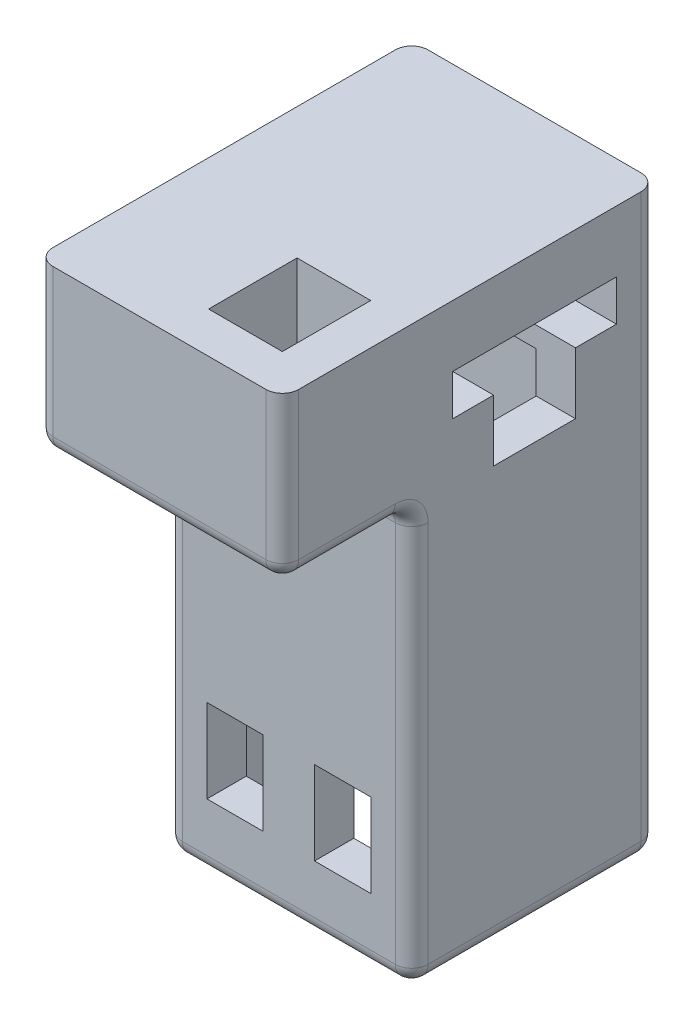
from build123d import *

# Parameters (mm, degrees)
SKETCH1_W           = 38.1
SKETCH1_H           = 38.1
BOSS_EXTRUDE1_DEPTH = 64.389
SKETCH2_W           = 8.720666582
SKETCH2_H           = 12.954
CUT_EXTRUDE1_DEPTH  = 38.1
SKETCH3_W           = 38.1
SKETCH3_H           = 38.1
BOSS_EXTRUDE2_DEPTH = 25.4
SKETCH1_3_W         = 25.908
SKETCH1_3_H         = 25.908
CUT_EXTRUDE2_DEPTH  = 70.739
CUT_EXTRUDE4_DEPTH  = 32.004
SKETCH7_W           = 38.1
SKETCH7_H           = 25.4
BOSS_EXTRUDE3_DEPTH = 20.066
SKETCH9_W           = 11.43
SKETCH9_H           = 13.716
CUT_EXTRUDE5_DEPTH  = 21.59
FILLET1_R           = 2.54


with BuildPart() as part:
    # Sketch1 → Boss-Extrude1 (new body)
    with BuildSketch(Plane(origin=(0, 0, 0), x_dir=(1, 0, 0), z_dir=(0, 1, 0))):
        Rectangle(SKETCH1_W, SKETCH1_H)
    extrude(amount=BOSS_EXTRUDE1_DEPTH)

    # Sketch2 → Cut-Extrude1 (cut)
    with BuildSketch(Plane.XY.offset(19.05)):
        with Locations((8.339666836, 16.637)):
            Rectangle(SKETCH2_W, SKETCH2_H)
        with Locations((-8.339666709, 16.637)):
            Rectangle(SKETCH2_W, SKETCH2_H)
    extrude(amount=-CUT_EXTRUDE1_DEPTH, mode=Mode.SUBTRACT)

    # Sketch3 → Boss-Extrude2 (add)
    with BuildSketch(Plane(origin=(0, 64.389, 0), x_dir=(-1, 0, 0), z_dir=(0, -1, 0))):
        Rectangle(SKETCH3_W, SKETCH3_H)
    extrude(amount=-BOSS_EXTRUDE2_DEPTH)

    # Sketch1_3 → Cut-Extrude2 (cut)
    with BuildSketch(Plane(origin=(0, 0, 0), x_dir=(1, 0, 0), z_dir=(0, 1, 0))):
        Rectangle(SKETCH1_3_W, SKETCH1_3_H)
    extrude(amount=CUT_EXTRUDE2_DEPTH, mode=Mode.SUBTRACT)

    # Sketch5 → Cut-Extrude4 (cut)
    with BuildSketch(Plane(origin=(19.05, 0, 0), x_dir=(0, 0, -1), z_dir=(1, 0, 0))):
        Polygon((-12.7, 80.264), (12.7, 80.264), (12.7, 73.914), (6.35, 73.914), (6.35, 64.389), (-6.35, 64.389), (-6.35, 73.914), (-12.7, 73.914), align=None)
    extrude(amount=-CUT_EXTRUDE4_DEPTH, mode=Mode.SUBTRACT)

    # Sketch7 → Boss-Extrude3 (add)
    with BuildSketch(Plane.XY.offset(19.05)):
        with Locations((0, 77.089)):
            Rectangle(SKETCH7_W, SKETCH7_H)
    extrude(amount=BOSS_EXTRUDE3_DEPTH)

    # Sketch9 → Cut-Extrude5 (cut)
    with BuildSketch(Plane(origin=(0, 89.789, 0), x_dir=(1, 0, 0), z_dir=(0, 1, 0))):
        with Locations((6.985, -25.908)):
            Rectangle(SKETCH9_W, SKETCH9_H)
    extrude(amount=-CUT_EXTRUDE5_DEPTH, mode=Mode.SUBTRACT)

    # Fillet1
    fillet1_edges = [part.edges().sort_by_distance(p)[0] for p in [
        (19.05, 32.1945, 19.05),
        (-19.05, 32.1945, 19.05),
        (0, 64.389, 19.05),
        (-19.05, 64.389, 29.083),
        (19.05, 64.389, 29.083),
        (-19.05, 77.089, 39.116),
        (0, 64.389, 39.116),
        (19.05, 77.089, 39.116),
        (0, 0, 19.05),
        (19.05, 0, 0),
        (0, 0, -19.05),
        (-19.05, 0, 0),
        (19.05, 44.8945, -19.05),
        (-19.05, 44.8945, -19.05),
    ]]
    fillet(fillet1_edges, radius=FILLET1_R)


solid = part.part
